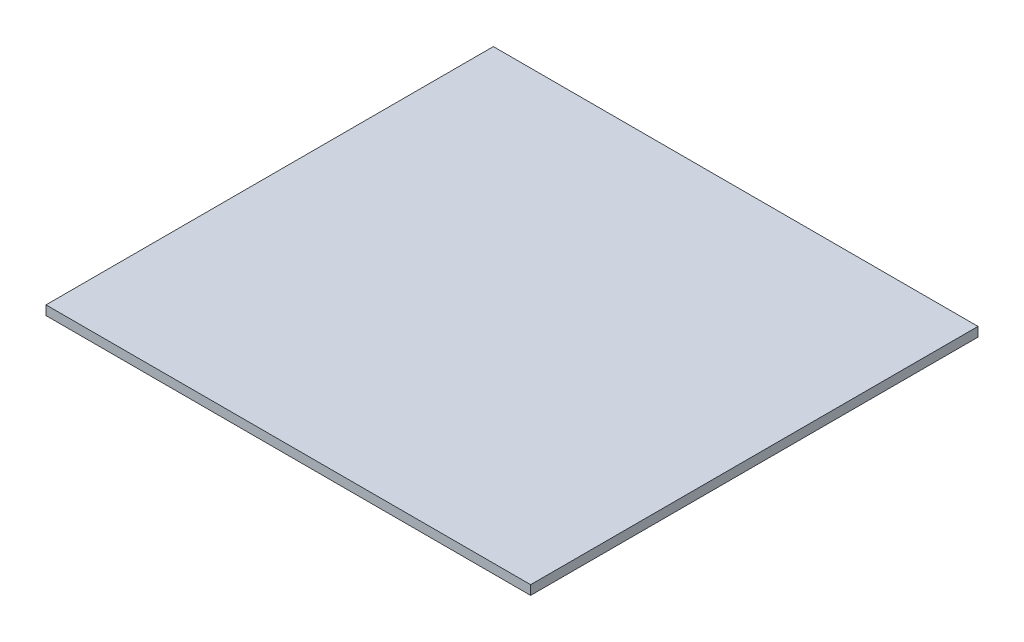
from build123d import *

# Parameters (mm, degrees)
SKETCH1_W           = 660.4
SKETCH1_H           = 609.6
BOSS_EXTRUDE1_DEPTH = 12.7


with BuildPart() as part:
    # Sketch1 → Boss-Extrude1 (new body)
    with BuildSketch(Plane(origin=(0, 0, 0), x_dir=(1, 0, 0), z_dir=(0, 1, 0))):
        with Locations((330.2, 304.8)):
            Rectangle(SKETCH1_W, SKETCH1_H)
    extrude(amount=BOSS_EXTRUDE1_DEPTH)


solid = part.part
